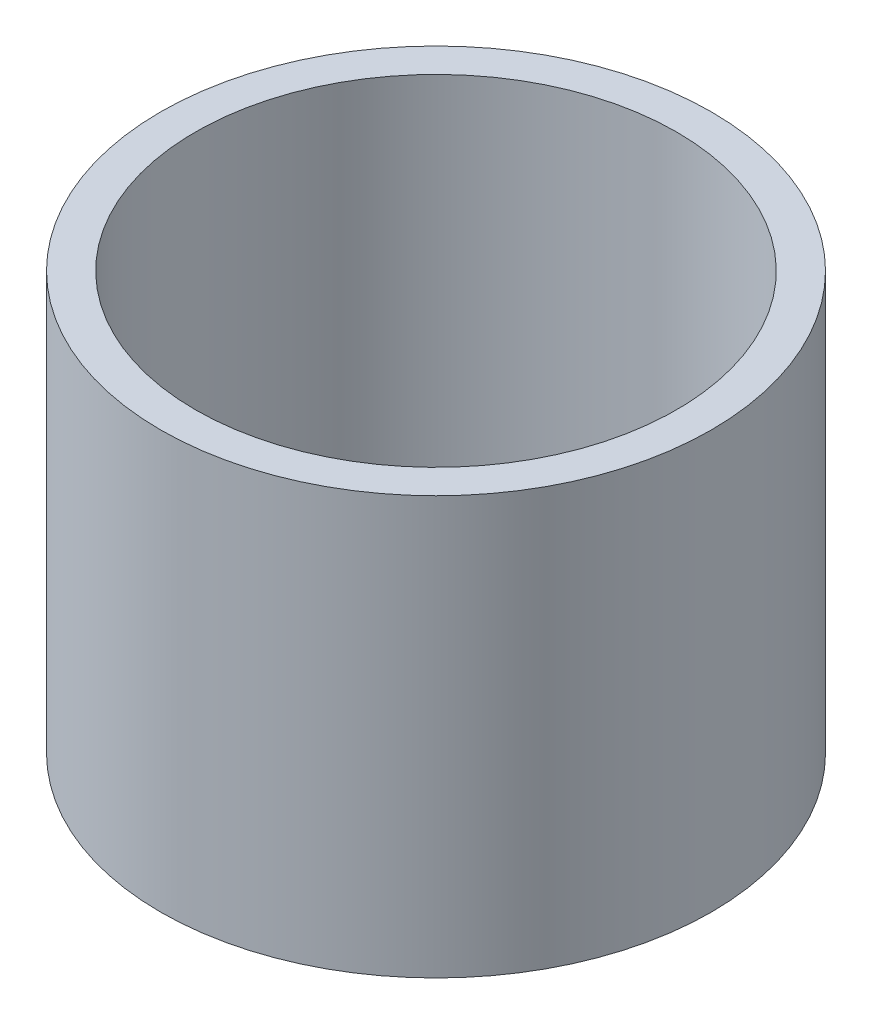
from build123d import *

# Parameters (mm, degrees)
SKETCH1_R           = 50.2539
SKETCH1_R_2         = 43.9039
BOSS_EXTRUDE1_DEPTH = 76.2


with BuildPart() as part:
    # Sketch1 → Boss-Extrude1 (new body)
    with BuildSketch(Plane(origin=(0, 0, 0), x_dir=(1, 0, 0), z_dir=(0, 1, 0))):
        Circle(SKETCH1_R)
        Circle(SKETCH1_R_2, mode=Mode.SUBTRACT)
    extrude(amount=BOSS_EXTRUDE1_DEPTH)


solid = part.part
